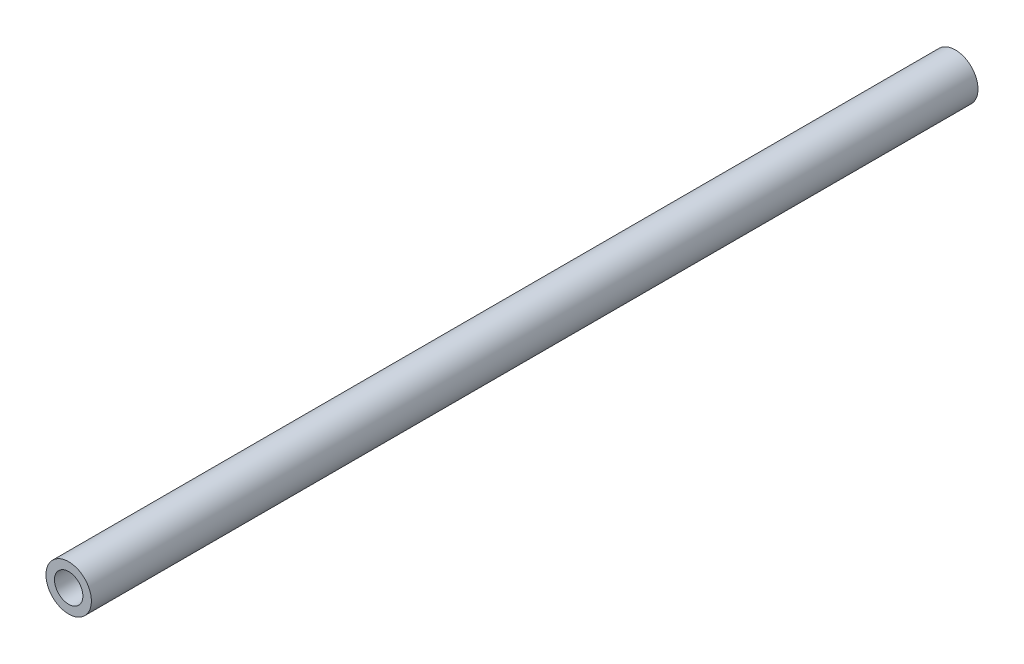
from build123d import *

# Parameters (mm, degrees)
SKETCH1_R           = 1.5875
BOSS_EXTRUDE1_DEPTH = 61.976
CUT_EXTRUDE1_REACH  = 63.976
SKETCH2_R           = 0.9921875


with BuildPart() as part:
    # Sketch1 → Boss-Extrude1 (new body)
    with BuildSketch(Plane.XY):
        Circle(SKETCH1_R)
    extrude(amount=BOSS_EXTRUDE1_DEPTH)

    # Sketch2 → Cut-Extrude1 (cut, up to next)
    with BuildSketch(Plane.XY.offset(61.976), mode=Mode.PRIVATE) as cut_extrude1_sk1:
        Circle(SKETCH2_R)
    cut_extrude1_tool1 = extrude(cut_extrude1_sk1.sketch, amount=-CUT_EXTRUDE1_REACH, mode=Mode.PRIVATE) & part.part
    add(cut_extrude1_tool1.solids().sort_by_distance((0, 0, 61.976))[0], mode=Mode.SUBTRACT)


solid = part.part
